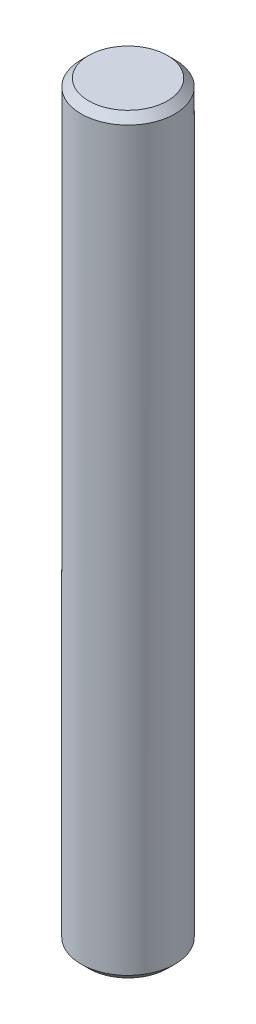
from build123d import *

# Parameters (mm, degrees)
SKETCH1_W     = 3.17119
SKETCH1_H     = 50.8
CHAMFER1_SIZE = 0.508
CHAMFER2_SIZE = 0.508


with BuildPart() as part:
    # Sketch1 → Revolve1 (revolve)
    with BuildSketch(Plane.XY):
        with Locations((1.585595, 25.4)):
            Rectangle(SKETCH1_W, SKETCH1_H)
    revolve(axis=Axis((0, 50.8, 0), (0, -1, 0)))

    # Chamfer1
    chamfer1_edges = [part.edges().sort_by_distance(p)[0] for p in [
        (-3.17119, 0, 0),
    ]]
    chamfer(chamfer1_edges, length=CHAMFER1_SIZE)

    # Chamfer2
    chamfer2_edges = [part.edges().sort_by_distance(p)[0] for p in [
        (-3.17119, 50.8, 0),
    ]]
    chamfer(chamfer2_edges, length=CHAMFER2_SIZE)


solid = part.part
